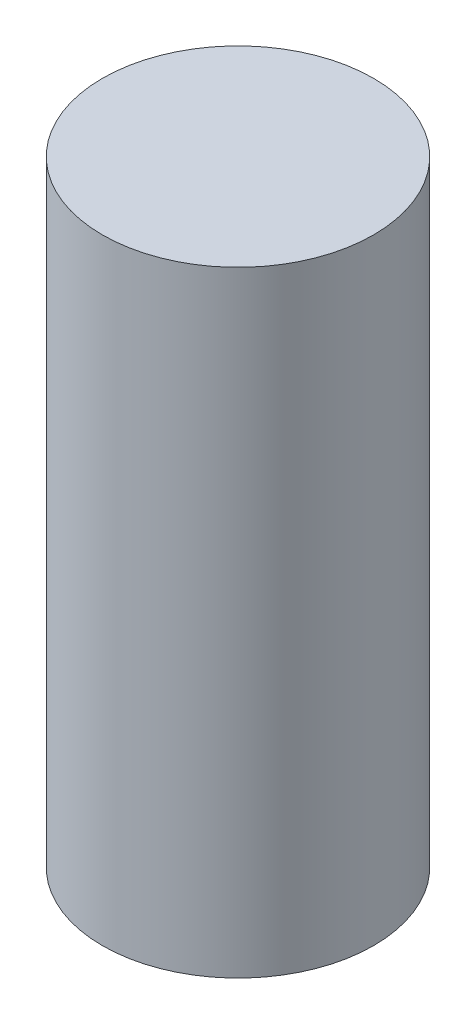
from build123d import *

# Parameters (mm, degrees)
SKETCH1_R           = 282.575
BOSS_EXTRUDE1_DEPTH = 1282.7


with BuildPart() as part:
    # Sketch1 → Boss-Extrude1 (new body)
    with BuildSketch(Plane(origin=(0, 0, 0), x_dir=(1, 0, 0), z_dir=(0, 1, 0))):
        Circle(SKETCH1_R)
    extrude(amount=BOSS_EXTRUDE1_DEPTH)


solid = part.part
